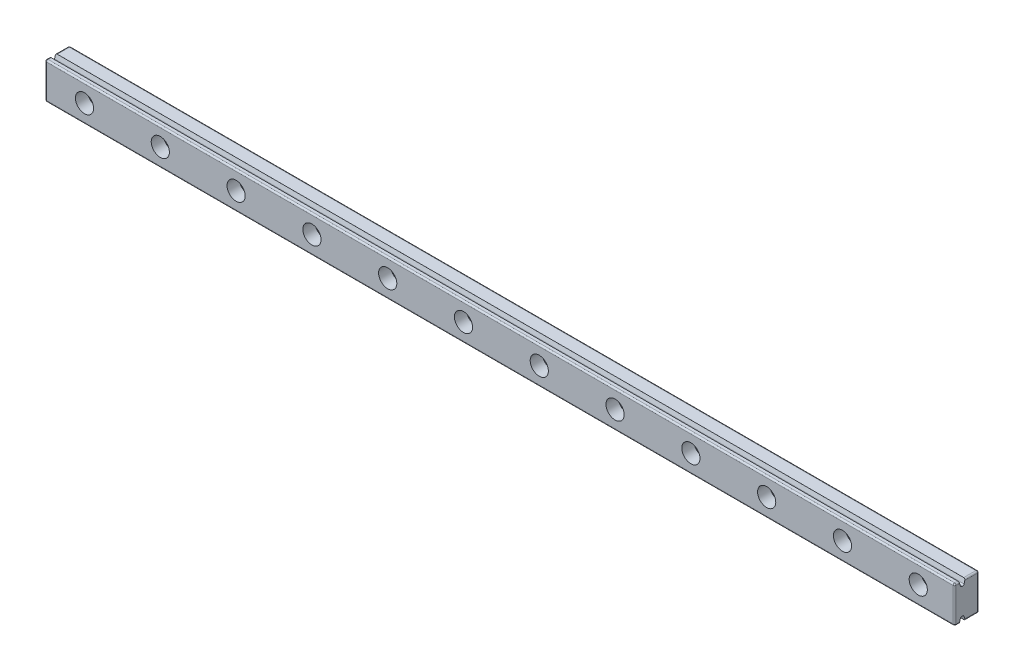
from build123d import *

# Parameters (mm, degrees)
BOSS_EXTRUDE1_DEPTH   = 300
SKETCH2_R             = 1.75
CUT_EXTRUDE1_DEPTH    = 10
SKETCH3_R             = 3
CUT_EXTRUDE2_DEPTH    = 4
CHAMFER1_SIZE         = 0.5
CHAMFER1_SIZE2        = 1.743707222
CHAMFER1_PART_2_SIZE  = 0.5
CHAMFER1_PART_2_SIZE2 = 1.743707222
FILLET1_R             = 0.5


with BuildPart() as part:
    # Sketch1 → Boss-Extrude1 (new body)
    with BuildSketch(Plane(origin=(0, 0, 0), x_dir=(0, 0, -1), z_dir=(1, 0, 0))):
        Polygon((-0.5, 6), (4, 6), (4, -6), (-0.5, -6), (-0.5, -4.25), (-2.5, -4.25), (-2.5, -6), (-4, -6), (-4, 6), (-2.5, 6), (-2.5, 4.25), (-0.5, 4.25), align=None)
    extrude(amount=BOSS_EXTRUDE1_DEPTH)

    # Sketch2 → Cut-Extrude1 (cut)
    with BuildSketch(Plane.XY.offset(4)):
        with Locations((13, 0)):
            Circle(SKETCH2_R)
        with Locations((38, 0)):
            Circle(SKETCH2_R)
        with Locations((63, 0)):
            Circle(SKETCH2_R)
        with Locations((88, 0)):
            Circle(SKETCH2_R)
        with Locations((113, 0)):
            Circle(SKETCH2_R)
        with Locations((138, 0)):
            Circle(SKETCH2_R)
        with Locations((163, 0)):
            Circle(SKETCH2_R)
        with Locations((188, 0)):
            Circle(SKETCH2_R)
        with Locations((213, 0)):
            Circle(SKETCH2_R)
        with Locations((238, 0)):
            Circle(SKETCH2_R)
        with Locations((263, 0)):
            Circle(SKETCH2_R)
        with Locations((288, 0)):
            Circle(SKETCH2_R)
        with Locations((313, 0)):
            Circle(SKETCH2_R)
        with Locations((338, 0)):
            Circle(SKETCH2_R)
        with Locations((363, 0)):
            Circle(SKETCH2_R)
        with Locations((388, 0)):
            Circle(SKETCH2_R)
    extrude(amount=-CUT_EXTRUDE1_DEPTH, mode=Mode.SUBTRACT)

    # Sketch3 → Cut-Extrude2 (cut)
    with BuildSketch(Plane.XY.offset(4)):
        with Locations((13, 0)):
            Circle(SKETCH3_R)
        with Locations((38, 0)):
            Circle(SKETCH3_R)
        with Locations((63, 0)):
            Circle(SKETCH3_R)
        with Locations((88, 0)):
            Circle(SKETCH3_R)
        with Locations((113, 0)):
            Circle(SKETCH3_R)
        with Locations((138, 0)):
            Circle(SKETCH3_R)
        with Locations((163, 0)):
            Circle(SKETCH3_R)
        with Locations((188, 0)):
            Circle(SKETCH3_R)
        with Locations((213, 0)):
            Circle(SKETCH3_R)
        with Locations((238, 0)):
            Circle(SKETCH3_R)
        with Locations((263, 0)):
            Circle(SKETCH3_R)
        with Locations((288, 0)):
            Circle(SKETCH3_R)
        with Locations((313, 0)):
            Circle(SKETCH3_R)
        with Locations((338, 0)):
            Circle(SKETCH3_R)
        with Locations((363, 0)):
            Circle(SKETCH3_R)
        with Locations((388, 0)):
            Circle(SKETCH3_R)
    extrude(amount=-CUT_EXTRUDE2_DEPTH, mode=Mode.SUBTRACT)

    # Chamfer1
    chamfer1_edges = [part.edges().sort_by_distance(p)[0] for p in [
        (150, -4.25, 0.5),
        (150, -4.25, 2.5),
    ]]
    chamfer1_side = [part.faces().sort_by_distance(p)[0] for p in [
        (150, -4.25, 1.5),
    ]]
    chamfer(chamfer1_edges, length=CHAMFER1_SIZE, length2=CHAMFER1_SIZE2, reference=chamfer1_side[0])

    # Chamfer1 part 2
    chamfer1_part_2_edges = [part.edges().sort_by_distance(p)[0] for p in [
        (150, 4.25, 2.5),
        (150, 4.25, 0.5),
    ]]
    chamfer1_part_2_side = [part.faces().sort_by_distance(p)[0] for p in [
        (150, 4.25, 1.5),
    ]]
    chamfer(chamfer1_part_2_edges, length=CHAMFER1_PART_2_SIZE, length2=CHAMFER1_PART_2_SIZE2, reference=chamfer1_part_2_side[0])

    # Fillet1
    fillet1_edges = [part.edges().sort_by_distance(p)[0] for p in [
        (300, -6, -1.75),
        (300, 0, -4),
        (300, 6, -1.75),
        (300, 6, 3.25),
        (300, 0, 4),
        (300, -6, 3.25),
        (0, -6, 3.25),
        (0, -6, -1.75),
        (0, 0, -4),
        (0, 6, -1.75),
        (0, 6, 3.25),
        (0, 0, 4),
        (150, -4.25, 1),
        (150, -4.25, 2),
        (150, 4.25, 2),
        (150, 4.25, 1),
        (150, -6, 4),
        (150, 6, 4),
        (150, -6, -4),
        (150, 6, -4),
    ]]
    fillet(fillet1_edges, radius=FILLET1_R)


solid = part.part
